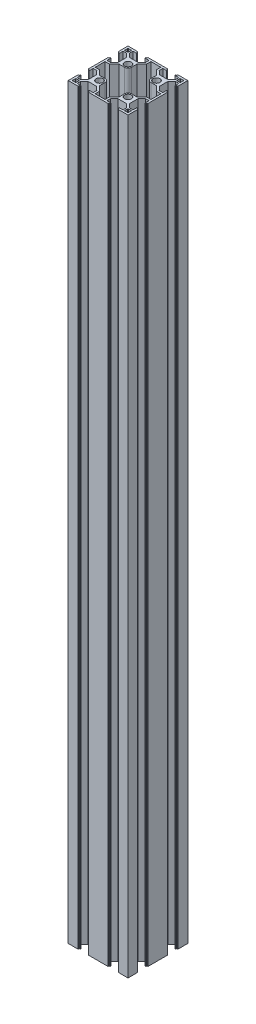
from build123d import *

# Parameters (mm, degrees)
SKETCH1_W                = 60
SKETCH1_H                = 60
BOSS_EXTRUDE1_DEPTH      = 750
CUT_EXTRUDE1_DEPTH       = 752.199041533
CIRPATTERN1_COUNT        = 4
CIRPATTERN1_COPY_1_DEPTH = 752.199041533
CIRPATTERN1_COPY_2_DEPTH = 752.199041533
CIRPATTERN1_COPY_3_DEPTH = 752.199041533
SKETCH4_R                = 3.4
CUT_EXTRUDE2_DEPTH       = 752.199041533
FILLET1_R                = 0.2
FILLET2_R                = 0.2
FILLET3_R                = 0.2
FILLET4_R                = 0.2


with BuildPart() as part:
    # Sketch1 → Boss-Extrude1 (new body)
    with BuildSketch(Plane(origin=(0, 0, 0), x_dir=(1, 0, 0), z_dir=(0, 1, 0))):
        Rectangle(SKETCH1_W, SKETCH1_H)
        Polygon((-23.05, -28), (-6.95, -28), (-6.95, -24.4), (-10.615, -20.8), (-19.385, -20.8), (-23.05, -24.4), align=None, mode=Mode.SUBTRACT)
        Polygon((10.615, -20.8), (19.385, -20.8), (23.05, -24.4), (23.05, -28), (6.95, -28), (6.95, -24.4), align=None, mode=Mode.SUBTRACT)
        Polygon((19.385, 20.8), (23.05, 24.4), (23.05, 28), (6.95, 28), (6.95, 24.4), (10.615, 20.8), align=None, mode=Mode.SUBTRACT)
        Polygon((-23.05, 24.4), (-23.05, 28), (-6.95, 28), (-6.95, 24.4), (-10.615, 20.8), (-19.385, 20.8), align=None, mode=Mode.SUBTRACT)
        Polygon((-20.8, 19.385), (-24.4, 23.05), (-28, 23.05), (-28, 6.95), (-24.4, 6.95), (-20.8, 10.615), align=None, mode=Mode.SUBTRACT)
        Polygon((-24.4, -23.05), (-28, -23.05), (-28, -6.95), (-24.4, -6.95), (-20.8, -10.615), (-20.8, -19.385), align=None, mode=Mode.SUBTRACT)
        Polygon((20.8, -19.385), (24.4, -23.05), (28, -23.05), (28, -6.95), (24.4, -6.95), (20.8, -10.615), align=None, mode=Mode.SUBTRACT)
        Polygon((24.4, 23.05), (28, 23.05), (28, 6.95), (24.4, 6.95), (20.8, 10.615), (20.8, 19.385), align=None, mode=Mode.SUBTRACT)
    extrude(amount=BOSS_EXTRUDE1_DEPTH)

    # Sketch2 → Cut-Extrude1 (cut, through all)
    with BuildSketch(Plane(origin=(0, 750, 0), x_dir=(1, 0, 0), z_dir=(0, 1, 0))):
        Polygon((-19.1, -28), (-19.1, -29), (-20.1, -29), (-20.1, -30), (-9.9, -30), (-9.9, -29), (-10.9, -29), (-10.9, -28), align=None)
    cut_extrude1 = extrude(amount=-CUT_EXTRUDE1_DEPTH, mode=Mode.SUBTRACT)

    # Mirror1: Cut-Extrude1 across plane
    add(cut_extrude1.mirror(Plane(origin=(0, 0, 0), x_dir=(0, 0, 1), z_dir=(1, 0, 0))), mode=Mode.SUBTRACT)

    # CirPattern1: Cut-Extrude1 ×4 about axis
    cirpattern1_axis = Axis((0, 1050, 0), (0, -1, 0))
    for i in range(1, CIRPATTERN1_COUNT):
        add(cut_extrude1.rotate(cirpattern1_axis, i * 360 / CIRPATTERN1_COUNT), mode=Mode.SUBTRACT)

    # CirPattern1 copy 1 sketch → CirPattern1 copy 1 (cut, through all)
    with BuildSketch(Plane(origin=(0, 750, 0), x_dir=(0, 0, -1), z_dir=(0, 1, 0))):
        Polygon((-19.1, 28), (-19.1, 29), (-20.1, 29), (-20.1, 30), (-9.9, 30), (-9.9, 29), (-10.9, 29), (-10.9, 28), align=None)
    extrude(amount=-CIRPATTERN1_COPY_1_DEPTH, mode=Mode.SUBTRACT)

    # CirPattern1 copy 2 sketch → CirPattern1 copy 2 (cut, through all)
    with BuildSketch(Plane(origin=(0, 750, 0), x_dir=(1, 0, 0), z_dir=(0, 1, 0))):
        Polygon((-19.1, 28), (-19.1, 29), (-20.1, 29), (-20.1, 30), (-9.9, 30), (-9.9, 29), (-10.9, 29), (-10.9, 28), align=None)
    extrude(amount=-CIRPATTERN1_COPY_2_DEPTH, mode=Mode.SUBTRACT)

    # CirPattern1 copy 3 sketch → CirPattern1 copy 3 (cut, through all)
    with BuildSketch(Plane.ZX.offset(750)):
        Polygon((-19.1, 28), (-19.1, 29), (-20.1, 29), (-20.1, 30), (-9.9, 30), (-9.9, 29), (-10.9, 29), (-10.9, 28), align=None)
    extrude(amount=-CIRPATTERN1_COPY_3_DEPTH, mode=Mode.SUBTRACT)

    # Sketch4 → Cut-Extrude2 (cut, through all)
    with BuildSketch(Plane(origin=(0, 750, 0), x_dir=(1, 0, 0), z_dir=(0, 1, 0))):
        with BuildLine():
            Line((-13.197035349, 9.797035349), (-18.8, 9.797035349))
            Line((-18.8, 9.797035349), (-23.561071557, 4.95))
            Line((-23.561071557, 4.95), (-28, 4.95))
            Line((-28, 4.95), (-28, -4.95))
            Line((-28, -4.95), (-23.561071557, -4.95))
            Line((-23.561071557, -4.95), (-18.8, -9.797035349))
            Line((-18.8, -9.797035349), (-13.197035349, -9.797035349))
            ThreePointArc((-13.197035349, -9.797035349), (-10.792872293, -10.792872293), (-9.797035349, -13.197035349))
            Line((-9.797035349, -13.197035349), (-9.797035349, -18.8))
            Line((-9.797035349, -18.8), (-4.95, -23.561071557))
            Line((-4.95, -23.561071557), (-4.95, -28))
            Line((-4.95, -28), (4.95, -28))
            Line((4.95, -28), (4.95, -23.561071557))
            Line((4.95, -23.561071557), (9.797035349, -18.8))
            Line((9.797035349, -18.8), (9.797035349, -13.197035349))
            ThreePointArc((9.797035349, -13.197035349), (10.792872293, -10.792872293), (13.197035349, -9.797035349))
            Line((13.197035349, -9.797035349), (18.8, -9.797035349))
            Line((18.8, -9.797035349), (23.561071557, -4.95))
            Line((23.561071557, -4.95), (28, -4.95))
            Line((28, -4.95), (28, 4.95))
            Line((28, 4.95), (23.561071557, 4.95))
            Line((23.561071557, 4.95), (18.8, 9.797035349))
            Line((18.8, 9.797035349), (13.197035349, 9.797035349))
            ThreePointArc((13.197035349, 9.797035349), (10.792872293, 10.792872293), (9.797035349, 13.197035349))
            Line((9.797035349, 13.197035349), (9.797035349, 18.8))
            Line((9.797035349, 18.8), (4.95, 23.561071557))
            Line((4.95, 23.561071557), (4.95, 28))
            Line((4.95, 28), (-4.95, 28))
            Line((-4.95, 28), (-4.95, 23.561071557))
            Line((-4.95, 23.561071557), (-9.797035349, 18.8))
            Line((-9.797035349, 18.8), (-9.797035349, 13.197035349))
            ThreePointArc((-9.797035349, 13.197035349), (-10.792872293, 10.792872293), (-13.197035349, 9.797035349))
        make_face()
        with BuildLine():
            ThreePointArc((-28, -27.5), (-27.853553391, -27.853553391), (-27.5, -28))
            Line((-27.5, -28), (-24.9, -28))
            ThreePointArc((-24.9, -28), (-24.546446609, -27.853553391), (-24.4, -27.5))
            Line((-24.4, -27.5), (-24.4, -24.9))
            ThreePointArc((-24.4, -24.9), (-24.546446609, -24.546446609), (-24.9, -24.4))
            Line((-24.9, -24.4), (-27.5, -24.4))
            ThreePointArc((-27.5, -24.4), (-27.853553391, -24.546446609), (-28, -24.9))
            Line((-28, -24.9), (-28, -27.5))
        make_face()
        with BuildLine():
            ThreePointArc((24.4, -27.5), (24.546446609, -27.853553391), (24.9, -28))
            Line((24.9, -28), (27.5, -28))
            ThreePointArc((27.5, -28), (27.853553391, -27.853553391), (28, -27.5))
            Line((28, -27.5), (28, -24.9))
            ThreePointArc((28, -24.9), (27.853553391, -24.546446609), (27.5, -24.4))
            Line((27.5, -24.4), (24.9, -24.4))
            ThreePointArc((24.9, -24.4), (24.546446609, -24.546446609), (24.4, -24.9))
            Line((24.4, -24.9), (24.4, -27.5))
        make_face()
        with BuildLine():
            ThreePointArc((-27.5, 28), (-27.853553391, 27.853553391), (-28, 27.5))
            Line((-28, 27.5), (-28, 24.9))
            ThreePointArc((-28, 24.9), (-27.853553391, 24.546446609), (-27.5, 24.4))
            Line((-27.5, 24.4), (-24.9, 24.4))
            ThreePointArc((-24.9, 24.4), (-24.546446609, 24.546446609), (-24.4, 24.9))
            Line((-24.4, 24.9), (-24.4, 27.5))
            ThreePointArc((-24.4, 27.5), (-24.546446609, 27.853553391), (-24.9, 28))
            Line((-24.9, 28), (-27.5, 28))
        make_face()
        with BuildLine():
            ThreePointArc((28, 27.5), (27.853553391, 27.853553391), (27.5, 28))
            Line((27.5, 28), (24.9, 28))
            ThreePointArc((24.9, 28), (24.546446609, 27.853553391), (24.4, 27.5))
            Line((24.4, 27.5), (24.4, 24.9))
            ThreePointArc((24.4, 24.9), (24.546446609, 24.546446609), (24.9, 24.4))
            Line((24.9, 24.4), (27.5, 24.4))
            ThreePointArc((27.5, 24.4), (27.853553391, 24.546446609), (28, 24.9))
            Line((28, 24.9), (28, 27.5))
        make_face()
        with Locations((14.298517674, 14.298517674)):
            Circle(SKETCH4_R)
        with Locations((14.298517674, -14.298517674)):
            Circle(SKETCH4_R)
        with Locations((-14.298517674, -14.298517674)):
            Circle(SKETCH4_R)
        with Locations((-14.298517674, 14.298517674)):
            Circle(SKETCH4_R)
    extrude(amount=-CUT_EXTRUDE2_DEPTH, mode=Mode.SUBTRACT)

    # Fillet1
    fillet1_edges = [part.edges().sort_by_distance(p)[0] for p in [
        (28, 375, -19.1),
        (30, 375, -20.1),
        (29, 375, -20.1),
        (29, 375, -19.1),
        (28, 375, 10.9),
        (29, 375, 9.9),
        (28, 375, 19.1),
        (29, 375, 20.1),
        (30, 375, 20.1),
        (29, 375, 19.1),
        (29, 375, 10.9),
        (30, 375, 9.9),
        (30, 375, -9.9),
        (29, 375, -9.9),
        (29, 375, -10.9),
        (28, 375, -10.9),
    ]]
    fillet(fillet1_edges, radius=FILLET1_R)

    # Fillet2
    fillet2_edges = [part.edges().sort_by_distance(p)[0] for p in [
        (-20.1, 0, -29.5),
        (-20.1, 750, -29.5),
        (-20.1, 375, -29),
        (-19.6, 0, -29),
        (-19.1, 375, -29),
        (-19.6, 750, -29),
        (-9.9, 375, -30),
        (-10.9, 375, -28),
        (-10.9, 375, -29),
        (-9.9, 375, -29),
        (19.1, 375, -28),
        (19.1, 375, -29),
        (20.1, 375, -29),
        (20.1, 375, -30),
        (10.9, 375, -28),
        (10.9, 375, -29),
        (9.9, 375, -29),
        (9.9, 375, -30),
        (-19.1, 375, -28),
        (-20.1, 375, -30),
    ]]
    fillet(fillet2_edges, radius=FILLET2_R)

    # Fillet3
    fillet3_edges = [part.edges().sort_by_distance(p)[0] for p in [
        (-29, 375, 9.9),
        (-29, 375, -20.1),
        (-30, 375, -20.1),
        (-29, 375, -19.1),
        (-28, 375, -10.9),
        (-29, 375, -10.9),
        (-29, 375, -9.9),
        (-30, 375, -9.9),
        (-29, 375, 10.9),
        (-30, 375, 9.9),
        (-28, 375, 19.1),
        (-29, 375, 19.1),
        (-29, 375, 20.1),
        (-30, 375, 20.1),
    ]]
    fillet(fillet3_edges, radius=FILLET3_R)

    # Fillet4
    fillet4_edges = [part.edges().sort_by_distance(p)[0] for p in [
        (-19.1, 375, 28),
        (10.9, 375, 28),
        (19.1, 375, 28),
        (20.1, 375, 29),
        (-10.9, 375, 28),
        (-9.9, 375, 29),
        (9.9, 375, 29),
        (-20.1, 375, 29),
        (19.1, 375, 29),
        (20.1, 375, 30),
        (10.9, 375, 29),
        (9.9, 375, 30),
        (-9.9, 375, 30),
        (-10.9, 375, 29),
        (-19.1, 375, 29),
        (-20.1, 375, 30),
    ]]
    fillet(fillet4_edges, radius=FILLET4_R)


solid = part.part
